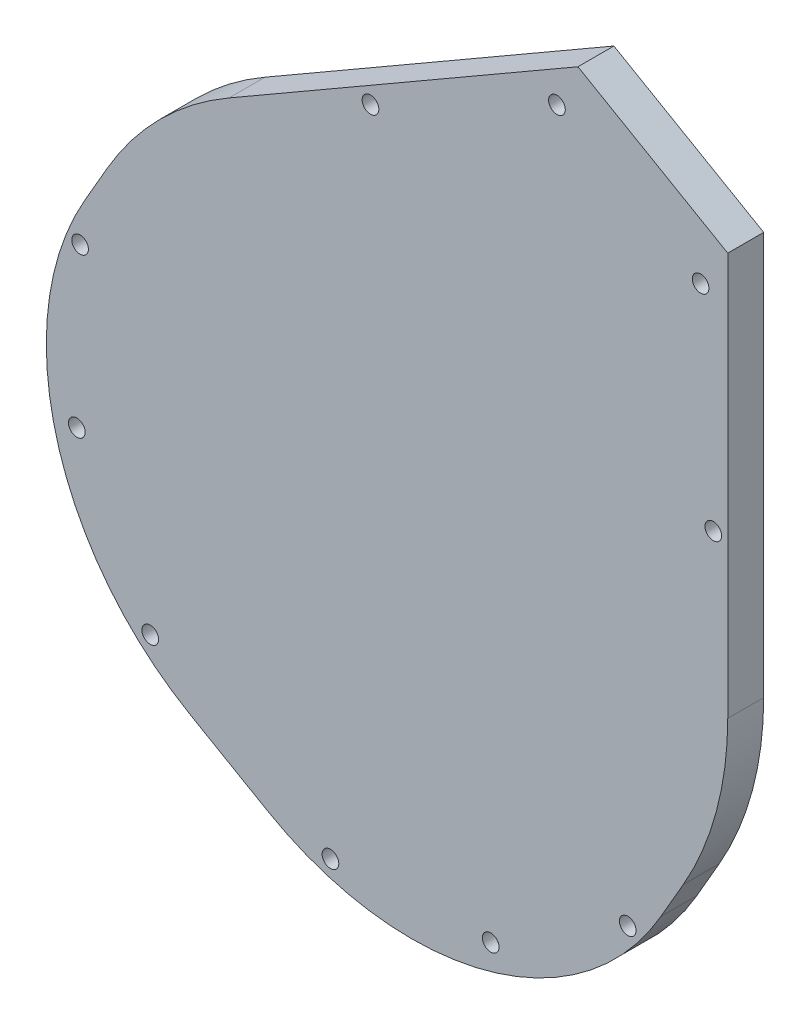
from build123d import *

# Parameters (mm, degrees)
BOSS_EXTRUDE2_DEPTH         = 6.35
F_4_CLEARANCE_HOLE1_D       = 2.9464
CUT_EXTRUDE2_DASH_048_DEPTH = 1.3208
FILLET1_R                   = 50.8


with BuildPart() as part:
    # Sketch3 → Boss-Extrude2 (new body)
    with BuildSketch(Plane(origin=(0.103482409, 1.991370524, 0), x_dir=(1, 0, 0), z_dir=(0, 0, 1))):
        with BuildLine():
            Line((58.7375, 0), (58.7375, 71.178534783))
            Line((58.7375, 71.178534783), (32.273669326, 86.457434546))
            Line((32.273669326, 86.457434546), (-29.36875, 50.868167155))
            ThreePointArc((-29.36875, 50.868167155), (-41.53368456, 41.53368456), (-50.868167155, 29.36875))
            Line((-50.868167155, 29.36875), (-80.236917155, -21.499417155))
            Line((-80.236917155, -21.499417155), (21.499417155, -80.236917155))
            Line((21.499417155, -80.236917155), (50.868167155, -29.36875))
            ThreePointArc((50.868167155, -29.36875), (56.736068222, -15.202383662), (58.7375, 0))
        make_face()
    extrude(amount=BOSS_EXTRUDE2_DEPTH)

    # #4 Clearance Hole1 (through all)
    with Locations(Plane.XY.offset(6.35)):
        with Locations((28.667480209, 80.767509471), (54.04362105, 66.116587726), (-4.272114917, 64.335461198), (-55.5710271, 17.274918559), (-56.146896149, -11.01373469), (-43.178667679, -36.217180003), (-11.345017944, -54.596346246), (16.965920195, -53.225438887), (41.176678022, -38.582395037), (56.282847372, 29.37403742)):
            Hole(F_4_CLEARANCE_HOLE1_D / 2)

    # Sketch6 → Cut-Extrude2 - dash 048 (cut)
    with BuildSketch(Plane(origin=(0.103482409, 1.991370524, 0), x_dir=(1, 0, 0), z_dir=(0, 0, 1))):
        with BuildLine():
            Line((55.672086916, 3.229866087), (52.009478425, 63.620294443))
            ThreePointArc((52.009478425, 63.620294443), (44.021350779, 76.247216167), (29.092051971, 76.851676775))
            Line((29.092051971, 76.851676775), (-25.038897376, 49.828374594))
            ThreePointArc((-25.038897376, 49.828374594), (-27.88285, -48.29451286), (55.672086916, 3.229866087))
        make_face()
        with BuildLine():
            Line((53.466162602, 3.099012969), (49.805143409, 63.46323641))
            ThreePointArc((49.805143409, 63.46323641), (42.916450779, 74.33347323), (30.058203233, 74.864137637))
            Line((30.058203233, 74.864137637), (-24.049257344, 47.852561541))
            ThreePointArc((-24.049257344, 47.852561541), (-26.77795, -46.380769923), (53.466162602, 3.099012969))
        make_face(mode=Mode.SUBTRACT)
    extrude(amount=CUT_EXTRUDE2_DASH_048_DEPTH, mode=Mode.SUBTRACT)

    # Fillet1
    fillet1_edges = [part.edges().sort_by_distance(p)[0] for p in [
        (21.602899564, -78.245546631, 3.175),
        (-80.133434745, -19.508046631, 3.175),
    ]]
    fillet(fillet1_edges, radius=FILLET1_R)


solid = part.part
